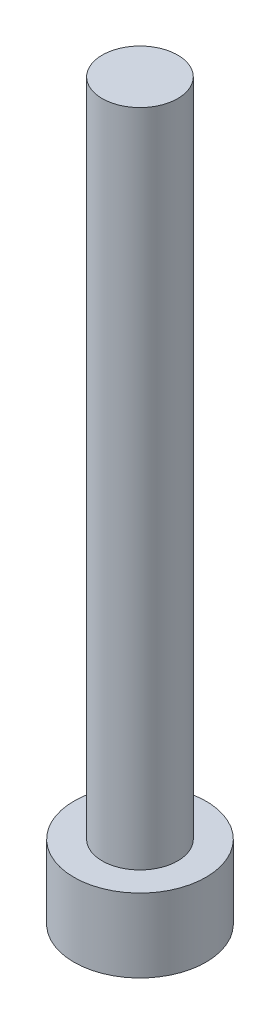
from build123d import *

# Parameters (mm, degrees)
SKETCH_1_R          = 3.5
EXTRUDE_1_DEPTH     = 3.9
SKETCH_2_R          = 2
EXTRUDE_2_DEPTH     = 35
CUT_EXTRUDE_1_DEPTH = 2.4


with BuildPart() as part:
    # 草图1 → 凸台-拉伸1 (new body)
    with BuildSketch(Plane(origin=(0, 0, 0), x_dir=(1, 0, 0), z_dir=(0, 1, 0))):
        Circle(SKETCH_1_R)
    extrude(amount=EXTRUDE_1_DEPTH)

    # 草图2 → 凸台-拉伸2 (add)
    with BuildSketch(Plane(origin=(0, 3.9, 0), x_dir=(1, 0, 0), z_dir=(0, 1, 0))):
        Circle(SKETCH_2_R)
    extrude(amount=EXTRUDE_2_DEPTH)

    # 草图3 → 切除-拉伸1 (cut)
    with BuildSketch(Plane.XZ):
        Polygon((1.725, 0), (0.8625, 1.493893822), (-0.8625, 1.493893822), (-1.725, 0), (-0.8625, -1.493893822), (0.8625, -1.493893822), align=None)
    extrude(amount=-CUT_EXTRUDE_1_DEPTH, mode=Mode.SUBTRACT)


solid = part.part
